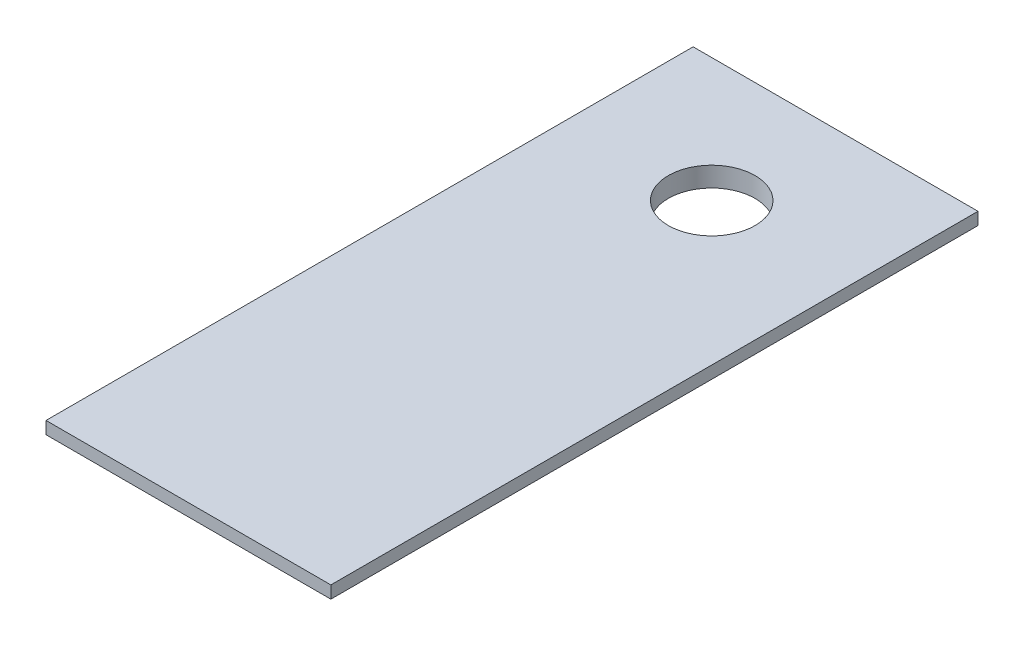
from build123d import *

# Parameters (mm, degrees)
SKETCH1_W           = 20
SKETCH1_H           = 49.25
BOSS_EXTRUDE1_DEPTH = 0.6
SKETCH2_W           = 23
SKETCH2_H           = 52.25
BOSS_EXTRUDE2_DEPTH = 1
SKETCH3_R           = 3.5
CUT_EXTRUDE1_DEPTH  = 10


with BuildPart() as part:
    # Sketch1 → Boss-Extrude1 (new body)
    with BuildSketch(Plane(origin=(0, 7.5, 0), x_dir=(1, 0, 0), z_dir=(0, 1, 0))):
        with Locations((10, 25.375)):
            Rectangle(SKETCH1_W, SKETCH1_H)
    extrude(amount=-BOSS_EXTRUDE1_DEPTH)

    # Sketch2 → Boss-Extrude2 (add)
    with BuildSketch(Plane(origin=(0, 7.5, 0), x_dir=(1, 0, 0), z_dir=(0, 1, 0))):
        with Locations((10, 25.375)):
            Rectangle(SKETCH2_W, SKETCH2_H)
    extrude(amount=BOSS_EXTRUDE2_DEPTH)

    # Sketch3 → Cut-Extrude1 (cut)
    with BuildSketch(Plane(origin=(0, 8.5, 0), x_dir=(1, 0, 0), z_dir=(0, 1, 0))):
        with Locations((10, 41.5)):
            Circle(SKETCH3_R)
    extrude(amount=-CUT_EXTRUDE1_DEPTH, mode=Mode.SUBTRACT)


solid = part.part
